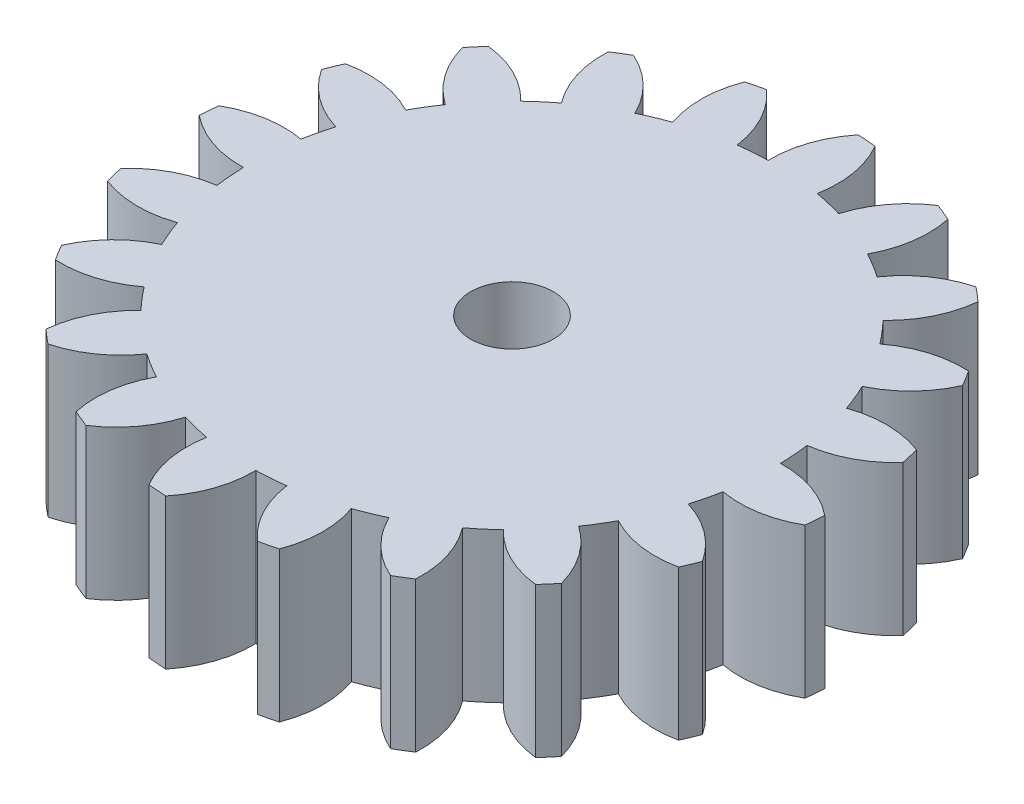
from build123d import *

# Parameters (mm, degrees)
EXTRUDE_1_DEPTH          = 10
SKETCH_2_R               = 2.752434458
CUT_EXTRUDE_1_DEPTH      = 1
CUT_EXTRUDE_1_DEPTH_BACK = 11


with BuildPart() as part:
    # 草图1 → 凸台-拉伸1 (new body)
    with BuildSketch(Plane(origin=(0, 0, 0), x_dir=(1, 0, 0), z_dir=(0, 1, 0))):
        with BuildLine():
            ThreePointArc((1.117051771, 21.971622501), (-0.045961741, 19.869637729), (-0.410530178, 17.495184051))
            ThreePointArc((-0.410530178, 17.495184051), (-1.373034175, 17.44605334), (-2.331373887, 17.344010372))
            ThreePointArc((-2.331373887, 17.344010372), (-3.062900273, 19.632199517), (-4.540418022, 21.526369972))
            ThreePointArc((-4.540418022, 21.526369972), (-5.135798005, 21.392138249), (-5.727225381, 21.241442734))
            ThreePointArc((-5.727225381, 21.241442734), (-6.183767943, 18.882945479), (-5.796746593, 16.512047994))
            ThreePointArc((-5.796746593, 16.512047994), (-6.696960066, 16.167891819), (-7.576862283, 15.774699932))
            ThreePointArc((-7.576862283, 15.774699932), (-8.979674551, 17.724843043), (-10.970208295, 19.069728104))
            ThreePointArc((-10.970208295, 19.069728104), (-11.494968424, 18.758083616), (-12.010881809, 18.432002554))
            ThreePointArc((-12.010881809, 18.432002554), (-11.716263855, 16.047858961), (-10.615537062, 13.912597632))
            ThreePointArc((-10.615537062, 13.912597632), (-11.365340846, 13.307104398), (-12.080674608, 12.661251953))
            ThreePointArc((-12.080674608, 12.661251953), (-14.017455719, 14.082455436), (-16.326158146, 14.746408382))
            ThreePointArc((-16.326158146, 14.746408382), (-16.728931243, 14.287857063), (-17.118829441, 13.818309541))
            ThreePointArc((-17.118829441, 13.818309541), (-16.101890228, 11.641896196), (-14.395204801, 9.95128528))
            ThreePointArc((-14.395204801, 9.95128528), (-14.921202876, 9.143724883), (-15.40194633, 8.308432417))
            ThreePointArc((-15.40194633, 8.308432417), (-17.683110656, 9.061578973), (-20.083989887, 8.979607464))
            ThreePointArc((-20.083989887, 8.979607464), (-20.325349715, 8.419035512), (-20.551066773, 7.851984112))
            ThreePointArc((-20.551066773, 7.851984112), (-18.911351397, 6.096343517), (-16.765769597, 5.01587179))
            ThreePointArc((-16.765769597, 5.01587179), (-17.016473607, 4.085293867), (-17.215568235, 3.142325628))
            ThreePointArc((-17.215568235, 3.142325628), (-19.617819516, 3.153692024), (-21.875860765, 2.333820002))
            ThreePointArc((-21.875860765, 2.333820002), (-21.932181342, 1.726100106), (-21.971622501, 1.117051771))
            ThreePointArc((-21.971622501, 1.117051771), (-19.869637729, -0.045961741), (-17.495184051, -0.410530178))
            ThreePointArc((-17.495184051, -0.410530178), (-17.44605334, -1.373034175), (-17.344010372, -2.331373887))
            ThreePointArc((-17.344010372, -2.331373887), (-19.632199517, -3.062900273), (-21.526369972, -4.540418022))
            ThreePointArc((-21.526369972, -4.540418022), (-21.392138249, -5.135798005), (-21.241442734, -5.727225381))
            ThreePointArc((-21.241442734, -5.727225381), (-18.882945479, -6.183767943), (-16.512047994, -5.796746593))
            ThreePointArc((-16.512047994, -5.796746593), (-16.167891819, -6.696960066), (-15.774699932, -7.576862283))
            ThreePointArc((-15.774699932, -7.576862283), (-17.724843043, -8.979674551), (-19.069728104, -10.970208295))
            ThreePointArc((-19.069728104, -10.970208295), (-18.758083616, -11.494968424), (-18.432002554, -12.010881809))
            ThreePointArc((-18.432002554, -12.010881809), (-16.047858961, -11.716263855), (-13.912597632, -10.615537062))
            ThreePointArc((-13.912597632, -10.615537062), (-13.307104398, -11.365340846), (-12.661251953, -12.080674608))
            ThreePointArc((-12.661251953, -12.080674608), (-14.082455436, -14.017455719), (-14.746408382, -16.326158146))
            ThreePointArc((-14.746408382, -16.326158146), (-14.287857063, -16.728931243), (-13.818309541, -17.118829441))
            ThreePointArc((-13.818309541, -17.118829441), (-11.641896196, -16.101890228), (-9.95128528, -14.395204801))
            ThreePointArc((-9.95128528, -14.395204801), (-9.143724883, -14.921202876), (-8.308432417, -15.40194633))
            ThreePointArc((-8.308432417, -15.40194633), (-9.061578973, -17.683110656), (-8.979607464, -20.083989887))
            ThreePointArc((-8.979607464, -20.083989887), (-8.419035512, -20.325349715), (-7.851984112, -20.551066773))
            ThreePointArc((-7.851984112, -20.551066773), (-6.096343517, -18.911351397), (-5.01587179, -16.765769597))
            ThreePointArc((-5.01587179, -16.765769597), (-4.085293867, -17.016473607), (-3.142325628, -17.215568235))
            ThreePointArc((-3.142325628, -17.215568235), (-3.153692024, -19.617819516), (-2.333820002, -21.875860765))
            ThreePointArc((-2.333820002, -21.875860765), (-1.726100106, -21.932181342), (-1.117051771, -21.971622501))
            ThreePointArc((-1.117051771, -21.971622501), (0.045961741, -19.869637729), (0.410530178, -17.495184051))
            ThreePointArc((0.410530178, -17.495184051), (1.373034175, -17.44605334), (2.331373887, -17.344010372))
            ThreePointArc((2.331373887, -17.344010372), (3.062900273, -19.632199517), (4.540418022, -21.526369972))
            ThreePointArc((4.540418022, -21.526369972), (5.135798005, -21.392138249), (5.727225381, -21.241442734))
            ThreePointArc((5.727225381, -21.241442734), (6.183767943, -18.882945479), (5.796746593, -16.512047994))
            ThreePointArc((5.796746593, -16.512047994), (6.696960066, -16.167891819), (7.576862283, -15.774699932))
            ThreePointArc((7.576862283, -15.774699932), (8.979674551, -17.724843043), (10.970208295, -19.069728104))
            ThreePointArc((10.970208295, -19.069728104), (11.494968424, -18.758083616), (12.010881809, -18.432002554))
            ThreePointArc((12.010881809, -18.432002554), (11.716263855, -16.047858961), (10.615537062, -13.912597632))
            ThreePointArc((10.615537062, -13.912597632), (11.365340846, -13.307104398), (12.080674608, -12.661251953))
            ThreePointArc((12.080674608, -12.661251953), (14.017455719, -14.082455436), (16.326158146, -14.746408382))
            ThreePointArc((16.326158146, -14.746408382), (16.728931243, -14.287857063), (17.118829441, -13.818309541))
            ThreePointArc((17.118829441, -13.818309541), (16.101890228, -11.641896196), (14.395204801, -9.95128528))
            ThreePointArc((14.395204801, -9.95128528), (14.921202876, -9.143724883), (15.40194633, -8.308432417))
            ThreePointArc((15.40194633, -8.308432417), (17.683110656, -9.061578973), (20.083989887, -8.979607464))
            ThreePointArc((20.083989887, -8.979607464), (20.325349715, -8.419035512), (20.551066773, -7.851984112))
            ThreePointArc((20.551066773, -7.851984112), (18.911351397, -6.096343517), (16.765769597, -5.01587179))
            ThreePointArc((16.765769597, -5.01587179), (17.016473607, -4.085293867), (17.215568235, -3.142325628))
            ThreePointArc((17.215568235, -3.142325628), (19.617819516, -3.153692024), (21.875860765, -2.333820002))
            ThreePointArc((21.875860765, -2.333820002), (21.932181342, -1.726100106), (21.971622501, -1.117051771))
            ThreePointArc((21.971622501, -1.117051771), (19.869637729, 0.045961741), (17.495184051, 0.410530178))
            ThreePointArc((17.495184051, 0.410530178), (17.44605334, 1.373034175), (17.344010372, 2.331373887))
            ThreePointArc((17.344010372, 2.331373887), (19.632199517, 3.062900273), (21.526369972, 4.540418022))
            ThreePointArc((21.526369972, 4.540418022), (21.392138249, 5.135798005), (21.241442734, 5.727225381))
            ThreePointArc((21.241442734, 5.727225381), (18.882945479, 6.183767943), (16.512047994, 5.796746593))
            ThreePointArc((16.512047994, 5.796746593), (16.167891819, 6.696960066), (15.774699932, 7.576862283))
            ThreePointArc((15.774699932, 7.576862283), (17.724843043, 8.979674551), (19.069728104, 10.970208295))
            ThreePointArc((19.069728104, 10.970208295), (18.758083616, 11.494968424), (18.432002554, 12.010881809))
            ThreePointArc((18.432002554, 12.010881809), (16.047858961, 11.716263855), (13.912597632, 10.615537062))
            ThreePointArc((13.912597632, 10.615537062), (13.307104398, 11.365340846), (12.661251953, 12.080674608))
            ThreePointArc((12.661251953, 12.080674608), (14.082455436, 14.017455719), (14.746408382, 16.326158146))
            ThreePointArc((14.746408382, 16.326158146), (14.287857063, 16.728931243), (13.818309541, 17.118829441))
            ThreePointArc((13.818309541, 17.118829441), (11.641896196, 16.101890228), (9.95128528, 14.395204801))
            ThreePointArc((9.95128528, 14.395204801), (9.143724883, 14.921202876), (8.308432417, 15.40194633))
            ThreePointArc((8.308432417, 15.40194633), (9.061578973, 17.683110656), (8.979607464, 20.083989887))
            ThreePointArc((8.979607464, 20.083989887), (8.419035512, 20.325349715), (7.851984112, 20.551066773))
            ThreePointArc((7.851984112, 20.551066773), (6.096343517, 18.911351397), (5.01587179, 16.765769597))
            ThreePointArc((5.01587179, 16.765769597), (4.085293867, 17.016473607), (3.142325628, 17.215568235))
            ThreePointArc((3.142325628, 17.215568235), (3.153692024, 19.617819516), (2.333820002, 21.875860765))
            ThreePointArc((2.333820002, 21.875860765), (1.726100106, 21.932181342), (1.117051771, 21.971622501))
        make_face()
    extrude(amount=EXTRUDE_1_DEPTH)

    # 草图2 → 切除-拉伸1 (cut, two sides)
    with BuildSketch(Plane(origin=(0, 10, 0), x_dir=(1, 0, 0), z_dir=(0, 1, 0))) as cut_extrude_1_sk:
        Circle(SKETCH_2_R)
    extrude(amount=CUT_EXTRUDE_1_DEPTH, mode=Mode.SUBTRACT)
    extrude(cut_extrude_1_sk.sketch, amount=-CUT_EXTRUDE_1_DEPTH_BACK, mode=Mode.SUBTRACT)


solid = part.part
